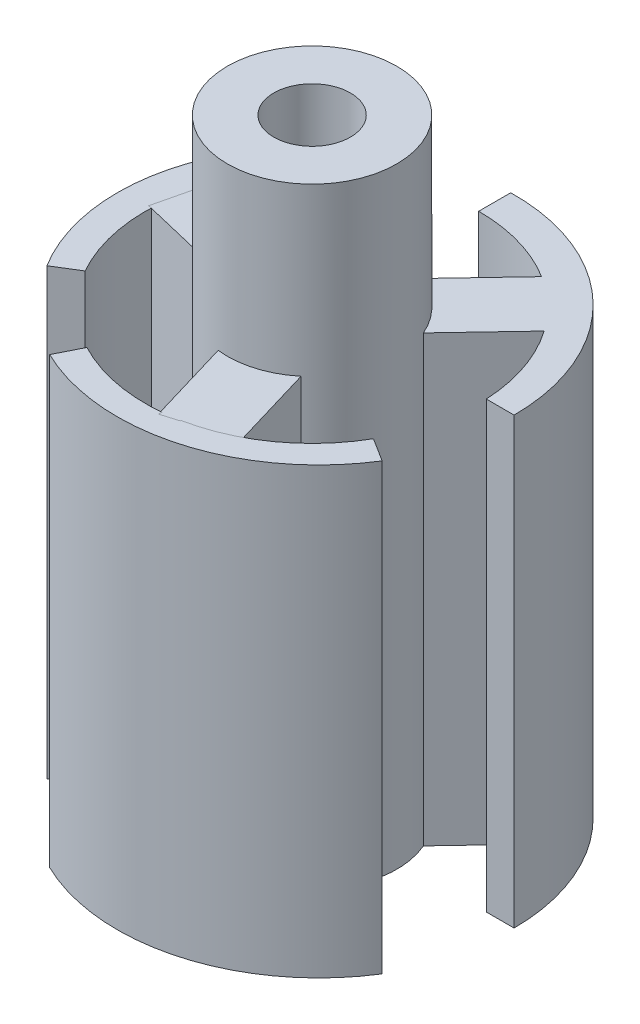
from build123d import *

# Parameters (mm, degrees)
BOSS_EXTRUDE6_DEPTH   = 40
BOSS_EXTRUDE6_2_DEPTH = 40
BOSS_EXTRUDE6_3_DEPTH = 40
SKETCH12_R            = 15
CUT_EXTRUDE9_DEPTH    = 40
BOSS_EXTRUDE8_DEPTH   = 40
SKETCH18_R            = 7.625
BOSS_EXTRUDE9_DEPTH   = 55
SKETCH22_R            = 3.45
CUT_EXTRUDE13_DEPTH   = 61.487275479


with BuildPart() as part:
    # Sketch11 → Boss-Extrude6 (new body)
    with BuildSketch(Plane(origin=(0, 0, 0), x_dir=(1, 0, 0), z_dir=(0, 1, 0))):
        with BuildLine():
            ThreePointArc((-9.349413612, 14.793189822), (-17.216152438, 4.282475359), (-15.190534929, -8.688938287))
            Line((-15.190534929, -8.688938287), (0, 0.700234787))
            Line((0, 0.700234787), (-9.349413612, 14.793189822))
        make_face()
    extrude(amount=BOSS_EXTRUDE6_DEPTH)


with BuildPart() as body_2:
    # Sketch11 → Boss-Extrude6 2 (new body)
    with BuildSketch(Plane(origin=(0, 0, 0), x_dir=(1, 0, 0), z_dir=(0, 1, 0))):
        with BuildLine():
            Line((0, 17.881636961), (0, 0.700234787))
            Line((0, 0.700234787), (17.485984995, 0.700234787))
            ThreePointArc((17.485984995, 0.700234787), (12.345670366, 12.957480113), (0, 17.881636961))
        make_face()
    extrude(amount=BOSS_EXTRUDE6_2_DEPTH)


with BuildPart() as body_3:
    # Sketch11 → Boss-Extrude6 3 (new body)
    with BuildSketch(Plane(origin=(0, 0, 0), x_dir=(1, 0, 0), z_dir=(0, 1, 0))):
        with BuildLine():
            Line((15.120108753, -8.810920002), (0, 0.700234787))
            Line((0, 0.700234787), (-8.136571383, -15.49342461))
            ThreePointArc((-8.136571383, -15.49342461), (4.767573461, -16.592271542), (15.120108753, -8.810920002))
        make_face()
    extrude(amount=BOSS_EXTRUDE6_3_DEPTH)


with BuildPart() as cut_extrude9_tool:
    # Sketch12 → Cut-Extrude9 (new body)
    with BuildSketch(Plane(origin=(0, 0, 0), x_dir=(1, 0, 0), z_dir=(0, 1, 0))):
        Circle(SKETCH12_R)
    extrude(amount=CUT_EXTRUDE9_DEPTH)


with BuildPart() as part_1:
    add(part.part)

    # Cut-Extrude9: cut by cut_extrude9_tool
    add(cut_extrude9_tool.part, mode=Mode.SUBTRACT)


with BuildPart() as body_2_1:
    add(body_2.part)

    # Cut-Extrude9: cut by cut_extrude9_tool
    add(cut_extrude9_tool.part, mode=Mode.SUBTRACT)



with BuildPart() as body_3_1:
    add(body_3.part)

    # Cut-Extrude9: cut by cut_extrude9_tool
    add(cut_extrude9_tool.part, mode=Mode.SUBTRACT)


with BuildPart() as body_4:
    # Sketch17 → Boss-Extrude8 (new body)
    with BuildSketch(Plane(origin=(0, 0, 0), x_dir=(1, 0, 0), z_dir=(0, 1, 0))):
        Polygon((-15.286299289, 0.573632321), (-2.382731506, -2.514476202), (1.394671955, -15.233347962), (7.146369483, -13.525139675), (3.368966021, -0.806267914), (12.495130342, 8.824495324), (8.139929807, 12.951507354), (-0.986234515, 3.320744116), (-13.889802298, 6.408852638), align=None)
    extrude(amount=BOSS_EXTRUDE8_DEPTH)


with BuildPart() as body_2_2:
    add(body_2_1.part)

    add(body_4.part)  # Boss-Extrude9 merges body 4
    # Sketch18 → Boss-Extrude9 (add)
    with BuildSketch(Plane(origin=(0, 0, 0), x_dir=(1, 0, 0), z_dir=(0, 1, 0))):
        with Locations(Location((0, 0, 0), (0, 0, 69.709879326))):
            Circle(SKETCH18_R)
    extrude(amount=BOSS_EXTRUDE9_DEPTH)

    # Sketch22 → Cut-Extrude13 (cut, through all)
    with BuildSketch(Plane(origin=(0, 0, 0), x_dir=(1, 0, 0), z_dir=(0, 1, 0))):
        with Locations(Location((0, 0, 0), (0, 0, 270))):
            Circle(SKETCH22_R)
    extrude(amount=CUT_EXTRUDE13_DEPTH, mode=Mode.SUBTRACT)


solid = Compound([part_1.part, body_3_1.part, body_2_2.part])
